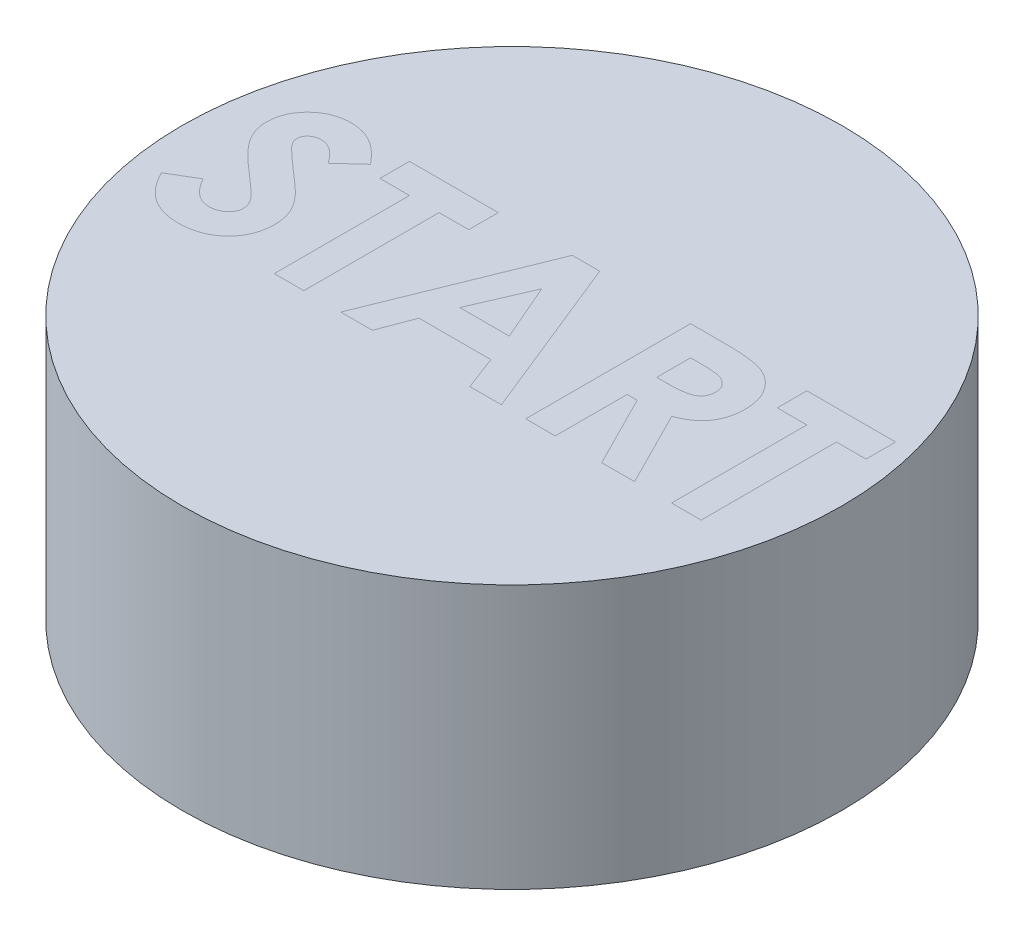
from build123d import *

# Parameters (mm, degrees)
SKETCH3_R               = 10
SKETCH3_W               = 2.15
SKETCH3_H               = 3.15
BOSS_EXTRUDE1_DEPTH     = 3
SKETCH4_R               = 10
BOSS_EXTRUDE2_DEPTH     = 5
CUT_EXTRUDE1_START      = 5
CUT_EXTRUDE1_DEPTH      = 16
CUT_EXTRUDE1_DEPTH_BACK = 0.4
BOSS_EXTRUDE3_START     = 5
BOSS_EXTRUDE3_DEPTH     = 0.4
BOSS_EXTRUDE3_2_DEPTH   = 0.4
BOSS_EXTRUDE3_3_DEPTH   = 0.4
BOSS_EXTRUDE3_4_DEPTH   = 0.4
BOSS_EXTRUDE3_5_DEPTH   = 0.4


with BuildPart() as part:
    # Sketch3 → Boss-Extrude1 (new body)
    with BuildSketch(Plane(origin=(0, 0, 0), x_dir=(1, 0, 0), z_dir=(0, 1, 0))):
        with Locations(Location((0, 0, 0), (0, 0, 270))):
            Circle(SKETCH3_R)
        Rectangle(SKETCH3_W, SKETCH3_H, mode=Mode.SUBTRACT)
    extrude(amount=-BOSS_EXTRUDE1_DEPTH)

    # Sketch4 → Boss-Extrude2 (add)
    with BuildSketch(Plane(origin=(0, 0, 0), x_dir=(1, 0, 0), z_dir=(0, 1, 0))):
        with Locations(Location((0, 0, 0), (0, 0, 270))):
            Circle(SKETCH4_R)
    extrude(amount=BOSS_EXTRUDE2_DEPTH)

    # Sketch5 → Cut-Extrude1 (cut, two sides)
    with BuildSketch(Plane(origin=(0, 0, 0), x_dir=(1, 0, 0), z_dir=(0, 1, 0)).offset(CUT_EXTRUDE1_START)) as cut_extrude1_sk:
        with BuildLine():
            Line((-6.121794872, 1.83193109), (-6.79286859, 1.217948718))
            add(Edge.make_bspline(
                [(-6.79286859, 1.217948718), (-6.82161451, 1.258497827), (-6.876802669, 1.336346463), (-6.966256918, 1.44058762), (-7.055307235, 1.529513085), (-7.144778618, 1.602751368), (-7.235464106, 1.659857492), (-7.327206283, 1.700289258), (-7.419485036, 1.725992116), (-7.481482114, 1.72919274), (-7.512019231, 1.730769231)],
                knots=[0, 0, 0, 0, 1.299362458, 2.494594718, 3.587462134, 4.587049575, 5.512617175, 6.380583204, 7.202344345, 8, 8, 8, 8], degree=3))
            add(Edge.make_bspline(
                [(-7.512019231, 1.730769231), (-7.540503377, 1.729770294), (-7.595498781, 1.727841609), (-7.673898808, 1.708670625), (-7.743503469, 1.675584321), (-7.804244832, 1.632321196), (-7.852360954, 1.580199161), (-7.890777945, 1.525536547), (-7.91240994, 1.465201384), (-7.915257136, 1.423760759), (-7.916666667, 1.403245192)],
                knots=[0, 0, 0, 0, 1.185010067, 2.2879431, 3.333075148, 4.379039566, 5.372662701, 6.27520591, 7.14612461, 8, 8, 8, 8], degree=3))
            add(Edge.make_bspline(
                [(-7.916666667, 1.403245192), (-7.915783385, 1.382433782), (-7.914004579, 1.340522492), (-7.89682373, 1.279096278), (-7.870927286, 1.219075717), (-7.846182176, 1.182538345), (-7.833533654, 1.163862179)],
                knots=[0, 0, 0, 0, 0.967525499, 1.948461899, 2.951351359, 4, 4, 4, 4], degree=3))
            add(Edge.make_bspline(
                [(-7.833533654, 1.163862179), (-7.822034779, 1.149345391), (-7.795565887, 1.115929662), (-7.745095131, 1.063004356), (-7.681714461, 0.998166224), (-7.602984856, 0.923644859), (-7.512174598, 0.83676018), (-7.405074514, 0.740927659), (-7.284767412, 0.633179473), (-7.199255911, 0.558147537), (-7.154447115, 0.518830128)],
                knots=[0, 0, 0, 0, 0.473873513, 1.090794244, 1.870441696, 2.795289791, 3.865433203, 5.087734844, 6.473946851, 8, 8, 8, 8], degree=3))
            add(Edge.make_bspline(
                [(-7.154447115, 0.518830128), (-7.112387615, 0.482429752), (-7.032567421, 0.4133494), (-6.918999135, 0.315300932), (-6.819191527, 0.227089116), (-6.731690627, 0.150037823), (-6.657822863, 0.083338608), (-6.597277695, 0.02667265), (-6.549315667, -0.01885687), (-6.522052062, -0.046356727), (-6.510416667, -0.058092949)],
                knots=[0, 0, 0, 0, 1.543621617, 2.929473131, 4.163658386, 5.240097082, 6.164993805, 6.925417477, 7.541396219, 8, 8, 8, 8], degree=3))
            add(Edge.make_bspline(
                [(-6.510416667, -0.058092949), (-6.466274403, -0.105864332), (-6.381417471, -0.197697706), (-6.271133372, -0.340010556), (-6.180365992, -0.478936916), (-6.110146625, -0.61709091), (-6.057114135, -0.756465826), (-6.019725528, -0.900479826), (-5.997333241, -1.050637766), (-5.994847175, -1.15310223), (-5.993589744, -1.204927885)],
                knots=[0, 0, 0, 0, 1.206664779, 2.319633467, 3.337109185, 4.282041471, 5.190008762, 6.099243693, 7.03861361, 8, 8, 8, 8], degree=3))
            add(Edge.make_bspline(
                [(-5.993589744, -1.204927885), (-5.994484751, -1.25542563), (-5.996240789, -1.354504084), (-6.017748886, -1.499490645), (-6.048418169, -1.638249076), (-6.095838262, -1.769269489), (-6.15363359, -1.894702545), (-6.22608838, -2.012594396), (-6.311176597, -2.124138155), (-6.408700758, -2.22733984), (-6.516574061, -2.320988217), (-6.632278431, -2.404356214), (-6.756945282, -2.473187115), (-6.889509482, -2.529864452), (-7.029900071, -2.573518094), (-7.177949802, -2.605782205), (-7.333885127, -2.625146615), (-7.44051595, -2.627170935), (-7.494991987, -2.628205128)],
                knots=[0, 0, 0, 0, 1.043214005, 2.046824704, 3.02475056, 3.976699089, 4.921714032, 5.875962561, 6.831408892, 7.817874052, 8.806269674, 9.781291748, 10.760897367, 11.74438705, 12.757449933, 13.795994037, 14.874007457, 16, 16, 16, 16], degree=3))
            add(Edge.make_bspline(
                [(-7.494991987, -2.628205128), (-7.537755213, -2.62744648), (-7.622450924, -2.625943922), (-7.747279597, -2.613676784), (-7.867815792, -2.593878928), (-7.983923736, -2.565502686), (-8.096126516, -2.52954614), (-8.204428739, -2.485626596), (-8.308082759, -2.433063317), (-8.407872871, -2.372937215), (-8.503313974, -2.30312289), (-8.595612881, -2.225047673), (-8.683852792, -2.137510733), (-8.768457506, -2.040719092), (-8.848885699, -1.934398657), (-8.927770073, -1.82003014), (-9.00160477, -1.695491014), (-9.047215746, -1.60812581), (-9.070512821, -1.563501603)],
                knots=[0, 0, 0, 0, 1.016823716, 2.013894106, 2.979844003, 3.91962641, 4.853723003, 5.779685073, 6.695824784, 7.614987388, 8.547259901, 9.504950863, 10.487499108, 11.500346958, 12.559593716, 13.656357062, 14.802919212, 16, 16, 16, 16], degree=3))
            Line((-9.070512821, -1.563501603), (-8.28125, -1.08974359))
            add(Edge.make_bspline(
                [(-8.28125, -1.08974359), (-8.252108842, -1.140397895), (-8.196242751, -1.237506528), (-8.101572438, -1.367984284), (-8.004587535, -1.479716883), (-7.903045839, -1.570729446), (-7.798182058, -1.642238927), (-7.689489676, -1.693344564), (-7.576892327, -1.724978895), (-7.500196129, -1.728842177), (-7.461939103, -1.730769231)],
                knots=[0, 0, 0, 0, 1.283663364, 2.460892379, 3.537111102, 4.529833553, 5.449777664, 6.316464042, 7.160231139, 8, 8, 8, 8], degree=3))
            add(Edge.make_bspline(
                [(-7.461939103, -1.730769231), (-7.42302623, -1.729195494), (-7.347529589, -1.726142216), (-7.239767796, -1.697940006), (-7.140967703, -1.653660467), (-7.055565633, -1.590479671), (-6.983252545, -1.517559429), (-6.929881334, -1.436432327), (-6.89635318, -1.34865476), (-6.892808442, -1.287678688), (-6.891025641, -1.257011218)],
                knots=[0, 0, 0, 0, 1.13588714, 2.203786484, 3.234766741, 4.283437687, 5.291419208, 6.222934724, 7.106237994, 8, 8, 8, 8], degree=3))
            add(Edge.make_bspline(
                [(-6.891025641, -1.257011218), (-6.892671984, -1.228480128), (-6.896016373, -1.170521949), (-6.92065011, -1.084347457), (-6.959160154, -0.998212155), (-7.004720253, -0.92756165), (-7.051083357, -0.868407897), (-7.095416943, -0.817153847), (-7.149403522, -0.760527094), (-7.212906209, -0.698456406), (-7.285085968, -0.63039536), (-7.366003601, -0.55635062), (-7.4565857, -0.476974432), (-7.520609306, -0.422904157), (-7.554086538, -0.39463141)],
                knots=[0, 0, 0, 0, 0.916159276, 1.861089862, 2.860218735, 3.940849679, 4.552606315, 5.27541173, 6.11797699, 7.06649574, 8.129236253, 9.306560635, 10.591630461, 12, 12, 12, 12], degree=3))
            add(Edge.make_bspline(
                [(-7.554086538, -0.39463141), (-7.61772809, -0.340784555), (-7.739875492, -0.23743614), (-7.912485267, -0.084793786), (-8.068022129, 0.057864481), (-8.205142696, 0.192302228), (-8.325594095, 0.316036702), (-8.428560577, 0.430072921), (-8.512911008, 0.535290519), (-8.601671649, 0.659913723), (-8.686012005, 0.81177566), (-8.758906005, 0.994483175), (-8.806196556, 1.177167507), (-8.811494805, 1.299811705), (-8.814102564, 1.360176282)],
                knots=[0, 0, 0, 0, 1.345494975, 2.582412109, 3.71882943, 4.751509156, 5.681369928, 6.505683931, 7.230279997, 7.856715994, 8.973648664, 10.023341002, 11.027102913, 12, 12, 12, 12], degree=3))
            add(Edge.make_bspline(
                [(-8.814102564, 1.360176282), (-8.813018001, 1.4029836), (-8.810881294, 1.487318614), (-8.791821541, 1.611320964), (-8.763336013, 1.730972813), (-8.721966849, 1.845837616), (-8.66827467, 1.955771501), (-8.603067603, 2.06131264), (-8.525333108, 2.161489655), (-8.437731579, 2.256236138), (-8.341217123, 2.342823641), (-8.238079161, 2.419245789), (-8.128901464, 2.483793046), (-8.014351925, 2.537339683), (-7.893720729, 2.578326232), (-7.76789656, 2.60737954), (-7.636698946, 2.624659522), (-7.547461161, 2.627008535), (-7.502003205, 2.628205128)],
                knots=[0, 0, 0, 0, 1.010766082, 1.991317756, 2.957454644, 3.913069143, 4.869106762, 5.843196583, 6.838735724, 7.860187025, 8.887984031, 9.89767229, 10.887916223, 11.879572884, 12.879850636, 13.892031539, 14.926195476, 16, 16, 16, 16], degree=3))
            add(Edge.make_bspline(
                [(-7.502003205, 2.628205128), (-7.443091944, 2.626050029), (-7.325734447, 2.621756841), (-7.152218003, 2.58818552), (-6.982734396, 2.535391081), (-6.846161328, 2.471700398), (-6.737492688, 2.410003203), (-6.654208326, 2.353200198), (-6.569462005, 2.288129303), (-6.482570298, 2.214585463), (-6.395147788, 2.131183014), (-6.304708634, 2.039907417), (-6.212485181, 1.939969839), (-6.152554559, 1.868574896), (-6.121794872, 1.83193109)],
                knots=[0, 0, 0, 0, 1.282922637, 2.555718331, 3.837320111, 5.142675274, 5.830281639, 6.55870424, 7.337177975, 8.157850921, 9.037902056, 9.96903443, 10.957596896, 12, 12, 12, 12], degree=3))
        make_face()
        Polygon((-5.608974359, 2.5), (-2.916666667, 2.5), (-2.916666667, 1.602564103), (-3.814102564, 1.602564103), (-3.814102564, -2.5), (-4.711538462, -2.5), (-4.711538462, 1.602564103), (-5.608974359, 1.602564103), align=None)
        Polygon((-0.672075321, 2.5), (0.16025641, 2.5), (2.179487179, -2.5), (1.220953526, -2.5), (0.832331731, -1.474358974), (-1.346153846, -1.474358974), (-1.734775641, -2.5), (-2.692307692, -2.5), align=None)
        Polygon((-0.256410256, 1.158854167), (-1.005608974, -0.576923077), (0.492788462, -0.576923077), align=None, mode=Mode.SUBTRACT)
        with BuildLine():
            Line((2.916666667, 2.5), (3.962339744, 2.5))
            add(Edge.make_bspline(
                [(3.962339744, 2.5), (4.031458416, 2.499754668), (4.164393092, 2.499282827), (4.356077634, 2.491838413), (4.532166247, 2.4814789), (4.692919646, 2.465670008), (4.838269057, 2.444709329), (4.968360156, 2.420000156), (5.083189139, 2.391838757), (5.183724431, 2.356747431), (5.27445256, 2.317164948), (5.359023791, 2.271683948), (5.439303889, 2.220810878), (5.514756269, 2.16320713), (5.58603663, 2.09990898), (5.653279448, 2.030852713), (5.715534517, 1.95545276), (5.772416353, 1.874185553), (5.824259568, 1.788694315), (5.870078097, 1.698861665), (5.907337801, 1.604625132), (5.940260743, 1.507346636), (5.963974072, 1.405635563), (5.980466345, 1.300482087), (5.992541342, 1.191516057), (5.993235597, 1.117489374), (5.993589744, 1.079727564)],
                knots=[0, 0, 0, 0, 1.749336639, 3.364467119, 4.854658419, 6.213483162, 7.451590619, 8.570285859, 9.5643256, 10.440900261, 11.26203566, 12.067320669, 12.869050712, 13.665104639, 14.467235401, 15.27997916, 16.102287765, 16.939272006, 17.78853747, 18.631303466, 19.488103222, 20.351255419, 21.228522269, 22.127379805, 23.044756219, 24, 24, 24, 24], degree=3))
            add(Edge.make_bspline(
                [(5.993589744, 1.079727564), (5.992669798, 1.040312909), (5.990865951, 0.963027954), (5.981149453, 0.849502658), (5.963390747, 0.740889596), (5.936492604, 0.637506773), (5.905576681, 0.53806747), (5.864466435, 0.444406403), (5.818069459, 0.355161409), (5.762965126, 0.271594891), (5.702490812, 0.19185067), (5.632160457, 0.118984044), (5.556530388, 0.049078706), (5.471349164, -0.01348671), (5.38037165, -0.07294265), (5.281790221, -0.126825567), (5.176248252, -0.176489951), (5.102047021, -0.204186242), (5.064102564, -0.218349359)],
                knots=[0, 0, 0, 0, 1.099860209, 2.156625411, 3.176576793, 4.16617041, 5.135385252, 6.078461593, 7.016046972, 7.938469504, 8.868247731, 9.803980173, 10.76021508, 11.73834243, 12.748633912, 13.790971185, 14.870363756, 16, 16, 16, 16], degree=3))
            Line((5.064102564, -0.218349359), (6.217948718, -2.5))
            Line((6.217948718, -2.5), (5.220352564, -2.5))
            Line((5.220352564, -2.5), (4.118589744, -0.320512821))
            Line((4.118589744, -0.320512821), (3.814102564, -0.320512821))
            Line((3.814102564, -0.320512821), (3.814102564, -2.5))
            Line((3.814102564, -2.5), (2.916666667, -2.5))
            Line((2.916666667, -2.5), (2.916666667, 2.5))
        make_face()
        with BuildLine():
            Line((3.814102564, 0.576923077), (4.163661859, 0.576923077))
            add(Edge.make_bspline(
                [(4.163661859, 0.576923077), (4.206398388, 0.577404404), (4.28822966, 0.578326043), (4.405913775, 0.582600986), (4.512799018, 0.592901485), (4.60934439, 0.605915781), (4.696035699, 0.620942666), (4.772099688, 0.642477103), (4.838708387, 0.665551798), (4.895072481, 0.694227658), (4.943228668, 0.72683833), (4.984808453, 0.763884865), (5.019200897, 0.806761511), (5.047507633, 0.854303067), (5.069527196, 0.906930027), (5.08559979, 0.964064664), (5.094581994, 1.026357817), (5.095615427, 1.069348574), (5.096153846, 1.091746795)],
                knots=[0, 0, 0, 0, 1.688639943, 3.233382647, 4.650958383, 5.928841754, 7.082724185, 8.122798841, 9.049171256, 9.863274652, 10.613301712, 11.341792392, 12.054588806, 12.776240173, 13.521029143, 14.301969904, 15.115324896, 16, 16, 16, 16], degree=3))
            add(Edge.make_bspline(
                [(5.096153846, 1.091746795), (5.095135915, 1.118245525), (5.093136377, 1.17029737), (5.073294752, 1.245233775), (5.041711171, 1.314592545), (4.998418732, 1.3780603), (4.943897534, 1.433700515), (4.881330157, 1.482747808), (4.809366247, 1.521530737), (4.742733081, 1.547111544), (4.682112475, 1.562416805), (4.627404291, 1.57382215), (4.564051885, 1.581905445), (4.492007428, 1.590479219), (4.411454565, 1.596038877), (4.321954235, 1.600096319), (4.223763481, 1.601756418), (4.1553152, 1.602287123), (4.119591346, 1.602564103)],
                knots=[0, 0, 0, 0, 1.020303359, 2.004196876, 2.966617323, 3.9489082, 4.950758222, 5.960522915, 7.003732012, 8.091992268, 8.70421221, 9.413913587, 10.24622431, 11.166358409, 12.212345909, 13.359657661, 14.621978493, 16, 16, 16, 16], degree=3))
            Line((4.119591346, 1.602564103), (3.814102564, 1.602564103))
            Line((3.814102564, 1.602564103), (3.814102564, 0.576923077))
        make_face(mode=Mode.SUBTRACT)
        Polygon((6.442307692, 2.5), (9.134615385, 2.5), (9.134615385, 1.602564103), (8.237179487, 1.602564103), (8.237179487, -2.5), (7.33974359, -2.5), (7.33974359, 1.602564103), (6.442307692, 1.602564103), align=None)
    extrude(amount=CUT_EXTRUDE1_DEPTH, mode=Mode.SUBTRACT)
    extrude(cut_extrude1_sk.sketch, amount=-CUT_EXTRUDE1_DEPTH_BACK, mode=Mode.SUBTRACT)


with BuildPart() as body_2:
    # Sketch5_2 → Boss-Extrude3 (new body)
    with BuildSketch(Plane(origin=(0, 0, 0), x_dir=(1, 0, 0), z_dir=(0, 1, 0)).offset(BOSS_EXTRUDE3_START)):
        with BuildLine():
            Line((-6.121794872, 1.83193109), (-6.79286859, 1.217948718))
            add(Edge.make_bspline(
                [(-6.79286859, 1.217948718), (-6.82161451, 1.258497827), (-6.876802669, 1.336346463), (-6.966256918, 1.44058762), (-7.055307235, 1.529513085), (-7.144778618, 1.602751368), (-7.235464106, 1.659857492), (-7.327206283, 1.700289258), (-7.419485036, 1.725992116), (-7.481482114, 1.72919274), (-7.512019231, 1.730769231)],
                knots=[0, 0, 0, 0, 1.299362458, 2.494594718, 3.587462134, 4.587049575, 5.512617175, 6.380583204, 7.202344345, 8, 8, 8, 8], degree=3))
            add(Edge.make_bspline(
                [(-7.512019231, 1.730769231), (-7.540503377, 1.729770294), (-7.595498781, 1.727841609), (-7.673898808, 1.708670625), (-7.743503469, 1.675584321), (-7.804244832, 1.632321196), (-7.852360954, 1.580199161), (-7.890777945, 1.525536547), (-7.91240994, 1.465201384), (-7.915257136, 1.423760759), (-7.916666667, 1.403245192)],
                knots=[0, 0, 0, 0, 1.185010067, 2.2879431, 3.333075148, 4.379039566, 5.372662701, 6.27520591, 7.14612461, 8, 8, 8, 8], degree=3))
            add(Edge.make_bspline(
                [(-7.916666667, 1.403245192), (-7.915783385, 1.382433782), (-7.914004579, 1.340522492), (-7.89682373, 1.279096278), (-7.870927286, 1.219075717), (-7.846182176, 1.182538345), (-7.833533654, 1.163862179)],
                knots=[0, 0, 0, 0, 0.967525499, 1.948461899, 2.951351359, 4, 4, 4, 4], degree=3))
            add(Edge.make_bspline(
                [(-7.833533654, 1.163862179), (-7.822034779, 1.149345391), (-7.795565887, 1.115929662), (-7.745095131, 1.063004356), (-7.681714461, 0.998166224), (-7.602984856, 0.923644859), (-7.512174598, 0.83676018), (-7.405074514, 0.740927659), (-7.284767412, 0.633179473), (-7.199255911, 0.558147537), (-7.154447115, 0.518830128)],
                knots=[0, 0, 0, 0, 0.473873513, 1.090794244, 1.870441696, 2.795289791, 3.865433203, 5.087734844, 6.473946851, 8, 8, 8, 8], degree=3))
            add(Edge.make_bspline(
                [(-7.154447115, 0.518830128), (-7.112387615, 0.482429752), (-7.032567421, 0.4133494), (-6.918999135, 0.315300932), (-6.819191527, 0.227089116), (-6.731690627, 0.150037823), (-6.657822863, 0.083338608), (-6.597277695, 0.02667265), (-6.549315667, -0.01885687), (-6.522052062, -0.046356727), (-6.510416667, -0.058092949)],
                knots=[0, 0, 0, 0, 1.543621617, 2.929473131, 4.163658386, 5.240097082, 6.164993805, 6.925417477, 7.541396219, 8, 8, 8, 8], degree=3))
            add(Edge.make_bspline(
                [(-6.510416667, -0.058092949), (-6.466274403, -0.105864332), (-6.381417471, -0.197697706), (-6.271133372, -0.340010556), (-6.180365992, -0.478936916), (-6.110146625, -0.61709091), (-6.057114135, -0.756465826), (-6.019725528, -0.900479826), (-5.997333241, -1.050637766), (-5.994847175, -1.15310223), (-5.993589744, -1.204927885)],
                knots=[0, 0, 0, 0, 1.206664779, 2.319633467, 3.337109185, 4.282041471, 5.190008762, 6.099243693, 7.03861361, 8, 8, 8, 8], degree=3))
            add(Edge.make_bspline(
                [(-5.993589744, -1.204927885), (-5.994484751, -1.25542563), (-5.996240789, -1.354504084), (-6.017748886, -1.499490645), (-6.048418169, -1.638249076), (-6.095838262, -1.769269489), (-6.15363359, -1.894702545), (-6.22608838, -2.012594396), (-6.311176597, -2.124138155), (-6.408700758, -2.22733984), (-6.516574061, -2.320988217), (-6.632278431, -2.404356214), (-6.756945282, -2.473187115), (-6.889509482, -2.529864452), (-7.029900071, -2.573518094), (-7.177949802, -2.605782205), (-7.333885127, -2.625146615), (-7.44051595, -2.627170935), (-7.494991987, -2.628205128)],
                knots=[0, 0, 0, 0, 1.043214005, 2.046824704, 3.02475056, 3.976699089, 4.921714032, 5.875962561, 6.831408892, 7.817874052, 8.806269674, 9.781291748, 10.760897367, 11.74438705, 12.757449933, 13.795994037, 14.874007457, 16, 16, 16, 16], degree=3))
            add(Edge.make_bspline(
                [(-7.494991987, -2.628205128), (-7.537755213, -2.62744648), (-7.622450924, -2.625943922), (-7.747279597, -2.613676784), (-7.867815792, -2.593878928), (-7.983923736, -2.565502686), (-8.096126516, -2.52954614), (-8.204428739, -2.485626596), (-8.308082759, -2.433063317), (-8.407872871, -2.372937215), (-8.503313974, -2.30312289), (-8.595612881, -2.225047673), (-8.683852792, -2.137510733), (-8.768457506, -2.040719092), (-8.848885699, -1.934398657), (-8.927770073, -1.82003014), (-9.00160477, -1.695491014), (-9.047215746, -1.60812581), (-9.070512821, -1.563501603)],
                knots=[0, 0, 0, 0, 1.016823716, 2.013894106, 2.979844003, 3.91962641, 4.853723003, 5.779685073, 6.695824784, 7.614987388, 8.547259901, 9.504950863, 10.487499108, 11.500346958, 12.559593716, 13.656357062, 14.802919212, 16, 16, 16, 16], degree=3))
            Line((-9.070512821, -1.563501603), (-8.28125, -1.08974359))
            add(Edge.make_bspline(
                [(-8.28125, -1.08974359), (-8.252108842, -1.140397895), (-8.196242751, -1.237506528), (-8.101572438, -1.367984284), (-8.004587535, -1.479716883), (-7.903045839, -1.570729446), (-7.798182058, -1.642238927), (-7.689489676, -1.693344564), (-7.576892327, -1.724978895), (-7.500196129, -1.728842177), (-7.461939103, -1.730769231)],
                knots=[0, 0, 0, 0, 1.283663364, 2.460892379, 3.537111102, 4.529833553, 5.449777664, 6.316464042, 7.160231139, 8, 8, 8, 8], degree=3))
            add(Edge.make_bspline(
                [(-7.461939103, -1.730769231), (-7.42302623, -1.729195494), (-7.347529589, -1.726142216), (-7.239767796, -1.697940006), (-7.140967703, -1.653660467), (-7.055565633, -1.590479671), (-6.983252545, -1.517559429), (-6.929881334, -1.436432327), (-6.89635318, -1.34865476), (-6.892808442, -1.287678688), (-6.891025641, -1.257011218)],
                knots=[0, 0, 0, 0, 1.13588714, 2.203786484, 3.234766741, 4.283437687, 5.291419208, 6.222934724, 7.106237994, 8, 8, 8, 8], degree=3))
            add(Edge.make_bspline(
                [(-6.891025641, -1.257011218), (-6.892671984, -1.228480128), (-6.896016373, -1.170521949), (-6.92065011, -1.084347457), (-6.959160154, -0.998212155), (-7.004720253, -0.92756165), (-7.051083357, -0.868407897), (-7.095416943, -0.817153847), (-7.149403522, -0.760527094), (-7.212906209, -0.698456406), (-7.285085968, -0.63039536), (-7.366003601, -0.55635062), (-7.4565857, -0.476974432), (-7.520609306, -0.422904157), (-7.554086538, -0.39463141)],
                knots=[0, 0, 0, 0, 0.916159276, 1.861089862, 2.860218735, 3.940849679, 4.552606315, 5.27541173, 6.11797699, 7.06649574, 8.129236253, 9.306560635, 10.591630461, 12, 12, 12, 12], degree=3))
            add(Edge.make_bspline(
                [(-7.554086538, -0.39463141), (-7.61772809, -0.340784555), (-7.739875492, -0.23743614), (-7.912485267, -0.084793786), (-8.068022129, 0.057864481), (-8.205142696, 0.192302228), (-8.325594095, 0.316036702), (-8.428560577, 0.430072921), (-8.512911008, 0.535290519), (-8.601671649, 0.659913723), (-8.686012005, 0.81177566), (-8.758906005, 0.994483175), (-8.806196556, 1.177167507), (-8.811494805, 1.299811705), (-8.814102564, 1.360176282)],
                knots=[0, 0, 0, 0, 1.345494975, 2.582412109, 3.71882943, 4.751509156, 5.681369928, 6.505683931, 7.230279997, 7.856715994, 8.973648664, 10.023341002, 11.027102913, 12, 12, 12, 12], degree=3))
            add(Edge.make_bspline(
                [(-8.814102564, 1.360176282), (-8.813018001, 1.4029836), (-8.810881294, 1.487318614), (-8.791821541, 1.611320964), (-8.763336013, 1.730972813), (-8.721966849, 1.845837616), (-8.66827467, 1.955771501), (-8.603067603, 2.06131264), (-8.525333108, 2.161489655), (-8.437731579, 2.256236138), (-8.341217123, 2.342823641), (-8.238079161, 2.419245789), (-8.128901464, 2.483793046), (-8.014351925, 2.537339683), (-7.893720729, 2.578326232), (-7.76789656, 2.60737954), (-7.636698946, 2.624659522), (-7.547461161, 2.627008535), (-7.502003205, 2.628205128)],
                knots=[0, 0, 0, 0, 1.010766082, 1.991317756, 2.957454644, 3.913069143, 4.869106762, 5.843196583, 6.838735724, 7.860187025, 8.887984031, 9.89767229, 10.887916223, 11.879572884, 12.879850636, 13.892031539, 14.926195476, 16, 16, 16, 16], degree=3))
            add(Edge.make_bspline(
                [(-7.502003205, 2.628205128), (-7.443091944, 2.626050029), (-7.325734447, 2.621756841), (-7.152218003, 2.58818552), (-6.982734396, 2.535391081), (-6.846161328, 2.471700398), (-6.737492688, 2.410003203), (-6.654208326, 2.353200198), (-6.569462005, 2.288129303), (-6.482570298, 2.214585463), (-6.395147788, 2.131183014), (-6.304708634, 2.039907417), (-6.212485181, 1.939969839), (-6.152554559, 1.868574896), (-6.121794872, 1.83193109)],
                knots=[0, 0, 0, 0, 1.282922637, 2.555718331, 3.837320111, 5.142675274, 5.830281639, 6.55870424, 7.337177975, 8.157850921, 9.037902056, 9.96903443, 10.957596896, 12, 12, 12, 12], degree=3))
        make_face()
    extrude(amount=-BOSS_EXTRUDE3_DEPTH)


with BuildPart() as body_3:
    # Sketch5_2 → Boss-Extrude3 2 (new body)
    with BuildSketch(Plane(origin=(0, 0, 0), x_dir=(1, 0, 0), z_dir=(0, 1, 0)).offset(BOSS_EXTRUDE3_START)):
        Polygon((-5.608974359, 2.5), (-2.916666667, 2.5), (-2.916666667, 1.602564103), (-3.814102564, 1.602564103), (-3.814102564, -2.5), (-4.711538462, -2.5), (-4.711538462, 1.602564103), (-5.608974359, 1.602564103), align=None)
    extrude(amount=-BOSS_EXTRUDE3_2_DEPTH)


with BuildPart() as body_4:
    # Sketch5_2 → Boss-Extrude3 3 (new body)
    with BuildSketch(Plane(origin=(0, 0, 0), x_dir=(1, 0, 0), z_dir=(0, 1, 0)).offset(BOSS_EXTRUDE3_START)):
        Polygon((-0.672075321, 2.5), (0.16025641, 2.5), (2.179487179, -2.5), (1.220953526, -2.5), (0.832331731, -1.474358974), (-1.346153846, -1.474358974), (-1.734775641, -2.5), (-2.692307692, -2.5), align=None)
        Polygon((-0.256410256, 1.158854167), (-1.005608974, -0.576923077), (0.492788462, -0.576923077), align=None, mode=Mode.SUBTRACT)
    extrude(amount=-BOSS_EXTRUDE3_3_DEPTH)


with BuildPart() as body_5:
    # Sketch5_2 → Boss-Extrude3 4 (new body)
    with BuildSketch(Plane(origin=(0, 0, 0), x_dir=(1, 0, 0), z_dir=(0, 1, 0)).offset(BOSS_EXTRUDE3_START)):
        with BuildLine():
            Line((2.916666667, 2.5), (3.962339744, 2.5))
            add(Edge.make_bspline(
                [(3.962339744, 2.5), (4.031458416, 2.499754668), (4.164393092, 2.499282827), (4.356077634, 2.491838413), (4.532166247, 2.4814789), (4.692919646, 2.465670008), (4.838269057, 2.444709329), (4.968360156, 2.420000156), (5.083189139, 2.391838757), (5.183724431, 2.356747431), (5.27445256, 2.317164948), (5.359023791, 2.271683948), (5.439303889, 2.220810878), (5.514756269, 2.16320713), (5.58603663, 2.09990898), (5.653279448, 2.030852713), (5.715534517, 1.95545276), (5.772416353, 1.874185553), (5.824259568, 1.788694315), (5.870078097, 1.698861665), (5.907337801, 1.604625132), (5.940260743, 1.507346636), (5.963974072, 1.405635563), (5.980466345, 1.300482087), (5.992541342, 1.191516057), (5.993235597, 1.117489374), (5.993589744, 1.079727564)],
                knots=[0, 0, 0, 0, 1.749336639, 3.364467119, 4.854658419, 6.213483162, 7.451590619, 8.570285859, 9.5643256, 10.440900261, 11.26203566, 12.067320669, 12.869050712, 13.665104639, 14.467235401, 15.27997916, 16.102287765, 16.939272006, 17.78853747, 18.631303466, 19.488103222, 20.351255419, 21.228522269, 22.127379805, 23.044756219, 24, 24, 24, 24], degree=3))
            add(Edge.make_bspline(
                [(5.993589744, 1.079727564), (5.992669798, 1.040312909), (5.990865951, 0.963027954), (5.981149453, 0.849502658), (5.963390747, 0.740889596), (5.936492604, 0.637506773), (5.905576681, 0.53806747), (5.864466435, 0.444406403), (5.818069459, 0.355161409), (5.762965126, 0.271594891), (5.702490812, 0.19185067), (5.632160457, 0.118984044), (5.556530388, 0.049078706), (5.471349164, -0.01348671), (5.38037165, -0.07294265), (5.281790221, -0.126825567), (5.176248252, -0.176489951), (5.102047021, -0.204186242), (5.064102564, -0.218349359)],
                knots=[0, 0, 0, 0, 1.099860209, 2.156625411, 3.176576793, 4.16617041, 5.135385252, 6.078461593, 7.016046972, 7.938469504, 8.868247731, 9.803980173, 10.76021508, 11.73834243, 12.748633912, 13.790971185, 14.870363756, 16, 16, 16, 16], degree=3))
            Line((5.064102564, -0.218349359), (6.217948718, -2.5))
            Line((6.217948718, -2.5), (5.220352564, -2.5))
            Line((5.220352564, -2.5), (4.118589744, -0.320512821))
            Line((4.118589744, -0.320512821), (3.814102564, -0.320512821))
            Line((3.814102564, -0.320512821), (3.814102564, -2.5))
            Line((3.814102564, -2.5), (2.916666667, -2.5))
            Line((2.916666667, -2.5), (2.916666667, 2.5))
        make_face()
        with BuildLine():
            Line((3.814102564, 0.576923077), (4.163661859, 0.576923077))
            add(Edge.make_bspline(
                [(4.163661859, 0.576923077), (4.206398388, 0.577404404), (4.28822966, 0.578326043), (4.405913775, 0.582600986), (4.512799018, 0.592901485), (4.60934439, 0.605915781), (4.696035699, 0.620942666), (4.772099688, 0.642477103), (4.838708387, 0.665551798), (4.895072481, 0.694227658), (4.943228668, 0.72683833), (4.984808453, 0.763884865), (5.019200897, 0.806761511), (5.047507633, 0.854303067), (5.069527196, 0.906930027), (5.08559979, 0.964064664), (5.094581994, 1.026357817), (5.095615427, 1.069348574), (5.096153846, 1.091746795)],
                knots=[0, 0, 0, 0, 1.688639943, 3.233382647, 4.650958383, 5.928841754, 7.082724185, 8.122798841, 9.049171256, 9.863274652, 10.613301712, 11.341792392, 12.054588806, 12.776240173, 13.521029143, 14.301969904, 15.115324896, 16, 16, 16, 16], degree=3))
            add(Edge.make_bspline(
                [(5.096153846, 1.091746795), (5.095135915, 1.118245525), (5.093136377, 1.17029737), (5.073294752, 1.245233775), (5.041711171, 1.314592545), (4.998418732, 1.3780603), (4.943897534, 1.433700515), (4.881330157, 1.482747808), (4.809366247, 1.521530737), (4.742733081, 1.547111544), (4.682112475, 1.562416805), (4.627404291, 1.57382215), (4.564051885, 1.581905445), (4.492007428, 1.590479219), (4.411454565, 1.596038877), (4.321954235, 1.600096319), (4.223763481, 1.601756418), (4.1553152, 1.602287123), (4.119591346, 1.602564103)],
                knots=[0, 0, 0, 0, 1.020303359, 2.004196876, 2.966617323, 3.9489082, 4.950758222, 5.960522915, 7.003732012, 8.091992268, 8.70421221, 9.413913587, 10.24622431, 11.166358409, 12.212345909, 13.359657661, 14.621978493, 16, 16, 16, 16], degree=3))
            Line((4.119591346, 1.602564103), (3.814102564, 1.602564103))
            Line((3.814102564, 1.602564103), (3.814102564, 0.576923077))
        make_face(mode=Mode.SUBTRACT)
    extrude(amount=-BOSS_EXTRUDE3_4_DEPTH)


with BuildPart() as body_6:
    # Sketch5_2 → Boss-Extrude3 5 (new body)
    with BuildSketch(Plane(origin=(0, 0, 0), x_dir=(1, 0, 0), z_dir=(0, 1, 0)).offset(BOSS_EXTRUDE3_START)):
        Polygon((6.442307692, 2.5), (9.134615385, 2.5), (9.134615385, 1.602564103), (8.237179487, 1.602564103), (8.237179487, -2.5), (7.33974359, -2.5), (7.33974359, 1.602564103), (6.442307692, 1.602564103), align=None)
    extrude(amount=-BOSS_EXTRUDE3_5_DEPTH)


solid = Compound([part.part, body_2.part, body_3.part, body_4.part, body_5.part, body_6.part])
